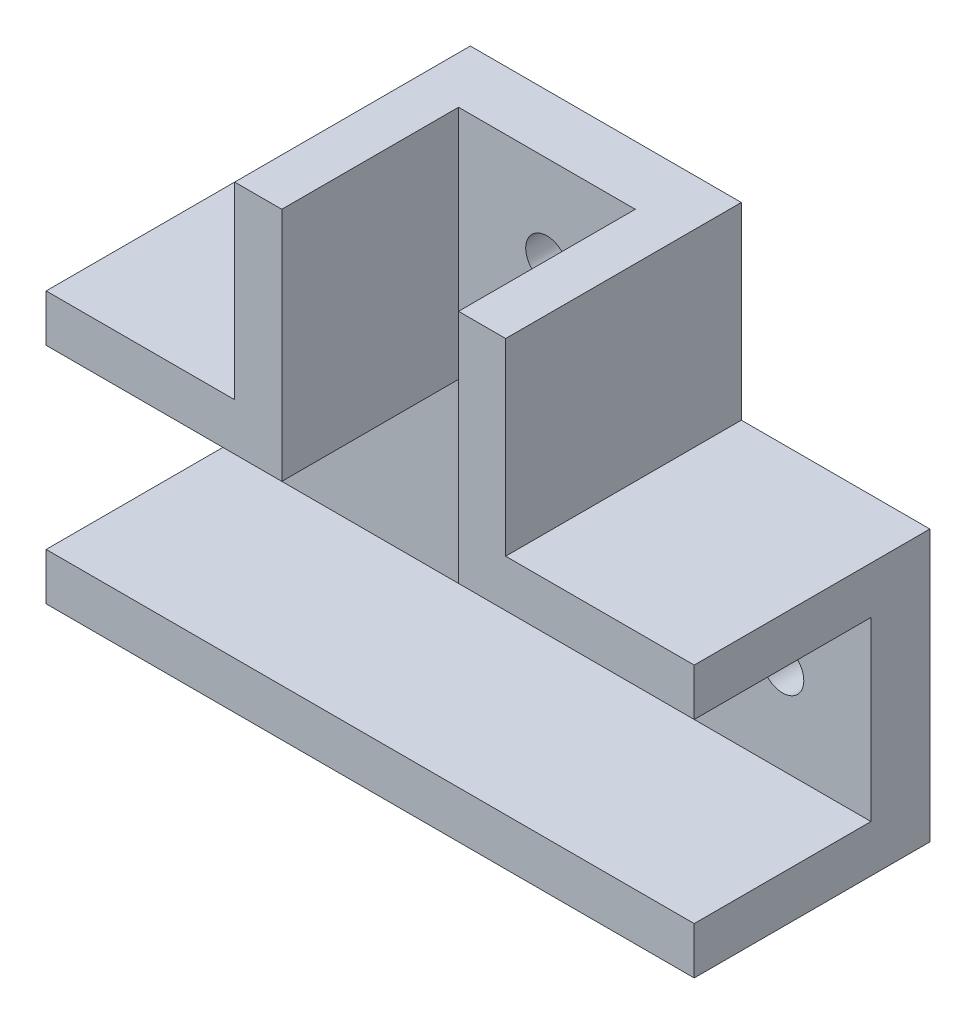
from build123d import *

# Parameters (mm, degrees)
BOSS_EXTRUDE1_DEPTH = 5
BOSS_EXTRUDE2_DEPTH = 20
SKETCH4_W           = 55
SKETCH4_H           = 4
BOSS_EXTRUDE3_DEPTH = 20
SKETCH6_R           = 1.8
CUT_EXTRUDE3_DEPTH  = 6


with BuildPart() as part:
    # Sketch1 → Boss-Extrude1 (new body)
    with BuildSketch(Plane.XY):
        Polygon((14.31372549, -4.264705882), (34.31372549, -4.264705882), (34.31372549, -19.264705882), (-20.68627451, -19.264705882), (-20.68627451, -4.264705882), (-0.68627451, -4.264705882), (-0.68627451, 15.735294118), (14.31372549, 15.735294118), align=None)
    extrude(amount=BOSS_EXTRUDE1_DEPTH)

    # Sketch2 → Boss-Extrude2 (add)
    with BuildSketch(Plane(origin=(0, 0, 0), x_dir=(-1, 0, 0), z_dir=(0, 0, -1))):
        Polygon((0.68627451, 15.735294118), (4.68627451, 15.735294118), (4.68627451, -0.264705882), (6.079970528, -0.264705882), (20.68627451, -0.264705882), (20.68627451, -4.264705882), (0.68627451, -4.264705882), align=None)
    boss_extrude2 = extrude(amount=-BOSS_EXTRUDE2_DEPTH)

    # Sketch4 → Boss-Extrude3 (add)
    with BuildSketch(Plane(origin=(0, 0, 0), x_dir=(-1, 0, 0), z_dir=(0, 0, -1))):
        with Locations((-6.81372549, -21.264705882)):
            Rectangle(SKETCH4_W, SKETCH4_H)
    extrude(amount=-BOSS_EXTRUDE3_DEPTH)

    # Mirror1: Boss-Extrude2 across plane
    add(boss_extrude2.mirror(Plane.ZY.offset(-6.81372549)))

    # Sketch6 → Cut-Extrude3 (cut, through all)
    with BuildSketch(Plane.XY.offset(5)):
        with Locations((6.81372549, 8.235294118)):
            Circle(SKETCH6_R)
        with Locations((-13.18627451, -11.764705882)):
            Circle(SKETCH6_R)
        with Locations((26.81372549, -11.764705882)):
            Circle(SKETCH6_R)
    extrude(amount=-CUT_EXTRUDE3_DEPTH, mode=Mode.SUBTRACT)


solid = part.part
